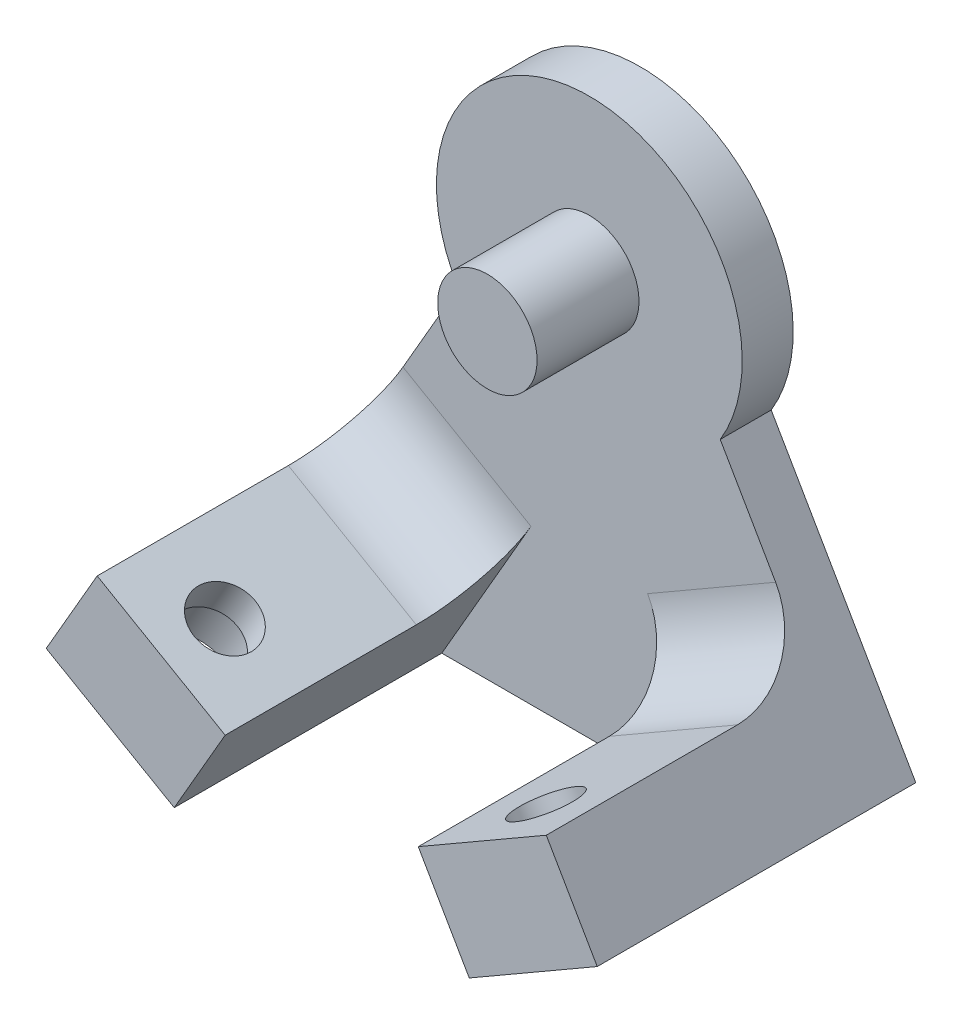
from build123d import *

# Parameters (mm, degrees)
EXTRUDE_1_DEPTH     = 2
EXTRUDE_2_DEPTH     = 10.5
SKETCH_3_R          = 1.95
EXTRUDE_3_DEPTH     = 4
FILLET_1_R          = 3
SKETCH_4_R          = 1.2
CUT_EXTRUDE_1_DEPTH = 28.201889258
SKETCH_5_R          = 2
CUT_EXTRUDE_2_DEPTH = 2.6


with BuildPart() as part:
    # 스케치1 → 보스-돌출1 (new body)
    with BuildSketch(Plane.XY):
        with BuildLine():
            Line((-8.811473671, -9.461920088), (-10.811473671, -12.926021703))
            Line((-10.811473671, -12.926021703), (-5.788526329, -15.826021703))
            Line((-5.788526329, -15.826021703), (5.788526329, -15.826021703))
            Line((5.788526329, -15.826021703), (10.811473671, -12.926021703))
            Line((10.811473671, -12.926021703), (8.811473671, -9.461920088))
            Line((8.811473671, -9.461920088), (5.137782868, -3.098900966))
            ThreePointArc((5.137782868, -3.098900966), (0, 6), (-5.137782868, -3.098900966))
            Line((-5.137782868, -3.098900966), (-8.811473671, -9.461920088))
        make_face()
    extrude(amount=EXTRUDE_1_DEPTH)

    # 스케치2 → 보스-돌출2 (add)
    with BuildSketch(Plane.XY.offset(2)):
        Polygon((-5.788526329, -15.826021703), (-10.811473671, -12.926021703), (-8.811473671, -9.461920088), (-3.788526329, -12.361920088), align=None)
        Polygon((5.788526329, -15.826021703), (3.788526329, -12.361920088), (8.811473671, -9.461920088), (10.811473671, -12.926021703), align=None)
    extrude(amount=EXTRUDE_2_DEPTH)

    # 스케치3 → 보스-돌출3 (add)
    with BuildSketch(Plane.XY.offset(2)):
        Circle(SKETCH_3_R)
    extrude(amount=EXTRUDE_3_DEPTH)

    # 필렛1
    fillet_1_edges = [part.edges().sort_by_distance(p)[0] for p in [
        (-6.3, -10.911920088, 2),
        (6.3, -10.911920088, 2),
    ]]
    fillet(fillet_1_edges, radius=FILLET_1_R)

    # 스케치4 → 컷-돌출1 (cut, through all)
    with BuildSketch(Plane(origin=(-8.3, -14.376021703, 0), x_dir=(0.866025404, -0.5, 0), z_dir=(-0.5, -0.866025404, 0))):
        with Locations((0, 10)):
            Circle(SKETCH_4_R)
    cut_extrude_1 = extrude(amount=-CUT_EXTRUDE_1_DEPTH, mode=Mode.SUBTRACT)

    # 스케치5 → 컷-돌출2 (cut)
    with BuildSketch(Plane(origin=(-8.3, -14.376021703, 0), x_dir=(0.866025404, -0.5, 0), z_dir=(-0.5, -0.866025404, 0))):
        with Locations((0, 10)):
            Circle(SKETCH_5_R)
    cut_extrude_2 = extrude(amount=-CUT_EXTRUDE_2_DEPTH, mode=Mode.SUBTRACT)

    # 대칭 복사1: 컷-돌출1, 컷-돌출2 across plane
    add(cut_extrude_1.mirror(Plane(origin=(0, 0, 0), x_dir=(0, 0, 1), z_dir=(1, 0, 0))), mode=Mode.SUBTRACT)
    add(cut_extrude_2.mirror(Plane(origin=(0, 0, 0), x_dir=(0, 0, 1), z_dir=(1, 0, 0))), mode=Mode.SUBTRACT)


solid = part.part
